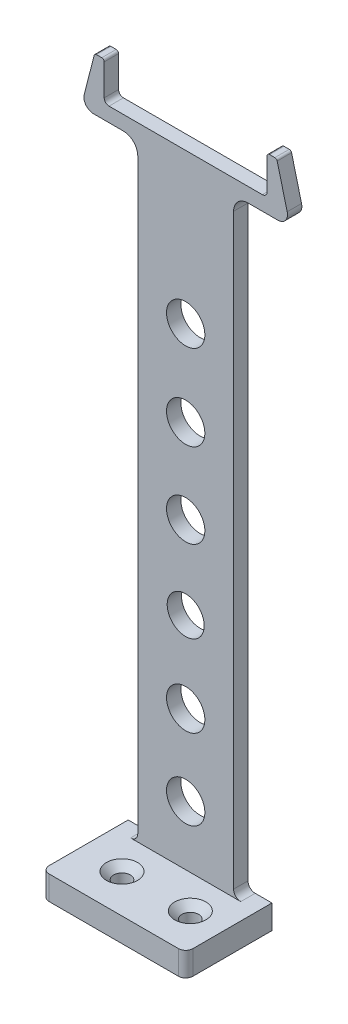
from build123d import *

# Parameters (mm, degrees)
BOSS_EXTRUDE1_DEPTH = 3
SKETCH2_W           = 30
SKETCH2_H           = 5
BOSS_EXTRUDE2_DEPTH = 15
SKETCH3_R           = 1.75
CUT_EXTRUDE1_DEPTH  = 6
CHAMFER1_SIZE       = 1.5
FILLET1_R           = 1.5
SKETCH4_R           = 4
SKETCH4_R_2         = 3.864560154
CUT_EXTRUDE2_DEPTH  = 15


with BuildPart() as part:
    # Sketch1 → Boss-Extrude1 (new body)
    with BuildSketch(Plane.XY):
        with BuildLine():
            Line((0, 124), (0, 0))
            Line((0, 0), (-5, 0))
            Line((-5, 0), (-5, -5))
            Line((-5, -5), (25, -5))
            Line((25, -5), (25, 0))
            Line((25, 0), (20, 0))
            Line((20, 0), (20, 124))
            ThreePointArc((20, 124), (20.878679656, 126.121320344), (23, 127))
            Line((23, 127), (29.241180609, 127))
            ThreePointArc((29.241180609, 127), (30.821169, 127.773771357), (31.17860763, 129.496363314))
            Line((31.17860763, 129.496363314), (29.096306865, 137.624090829))
            ThreePointArc((29.096306865, 137.624090829), (28.918507271, 137.894997098), (28.61195011, 138))
            Line((28.61195011, 138), (27.5, 138))
            ThreePointArc((27.5, 138), (27.146446609, 137.853553391), (27, 137.5))
            Line((27, 137.5), (27, 131))
            ThreePointArc((27, 131), (26.707106781, 130.292893219), (26, 130))
            Line((26, 130), (20, 130))
            Line((20, 130), (-6, 130))
            ThreePointArc((-6, 130), (-6.707106781, 130.292893219), (-7, 131))
            Line((-7, 131), (-7, 137.5))
            ThreePointArc((-7, 137.5), (-7.146446609, 137.853553391), (-7.5, 138))
            Line((-7.5, 138), (-8.61195011, 138))
            ThreePointArc((-8.61195011, 138), (-8.918507271, 137.894997098), (-9.096306865, 137.624090829))
            Line((-9.096306865, 137.624090829), (-11.17860763, 129.496363314))
            ThreePointArc((-11.17860763, 129.496363314), (-10.821169, 127.773771357), (-9.241180609, 127))
            Line((-9.241180609, 127), (-3, 127))
            ThreePointArc((-3, 127), (-0.878679656, 126.121320344), (0, 124))
        make_face()
    extrude(amount=BOSS_EXTRUDE1_DEPTH)

    # Sketch2 → Boss-Extrude2 (add)
    with BuildSketch(Plane.XY.offset(3)):
        with Locations((10, -2.5)):
            Rectangle(SKETCH2_W, SKETCH2_H)
    extrude(amount=BOSS_EXTRUDE2_DEPTH)

    # Sketch3 → Cut-Extrude1 (cut, through all)
    with BuildSketch(Plane(origin=(0, 0, 0), x_dir=(1, 0, 0), z_dir=(0, 1, 0))):
        with Locations((3.659677637, -9.948594681)):
            Circle(SKETCH3_R)
        with Locations((17.916573173, -9.948594681)):
            Circle(SKETCH3_R)
    extrude(amount=-CUT_EXTRUDE1_DEPTH, mode=Mode.SUBTRACT)

    # Chamfer1
    chamfer1_edges = [part.edges().sort_by_distance(p)[0] for p in [
        (1.909677637, 0, 9.948594681),
        (16.166573173, 0, 9.948594681),
    ]]
    chamfer(chamfer1_edges, length=CHAMFER1_SIZE)

    # Fillet1
    fillet1_edges = [part.edges().sort_by_distance(p)[0] for p in [
        (20, 0, 1.5),
        (0, 0, 1.5),
        (-5, -2.5, 18),
        (25, -2.5, 18),
    ]]
    fillet(fillet1_edges, radius=FILLET1_R)

    # Sketch4 → Cut-Extrude2 (cut)
    with BuildSketch(Plane(origin=(0, 0, 0), x_dir=(-1, 0, 0), z_dir=(0, 0, -1))):
        with Locations((-10, 12.348743191)):
            Circle(SKETCH4_R)
        with Locations((-10, 63.263754521)):
            Circle(SKETCH4_R)
        with Locations((-10, 29.11719238)):
            Circle(SKETCH4_R)
        with Locations((-10, 98.668347899)):
            Circle(SKETCH4_R)
        with Locations((-10, 46.010754702)):
            Circle(SKETCH4_R_2)
        with Locations((-10, 80.876191836)):
            Circle(SKETCH4_R)
    extrude(amount=-CUT_EXTRUDE2_DEPTH, mode=Mode.SUBTRACT)


solid = part.part
